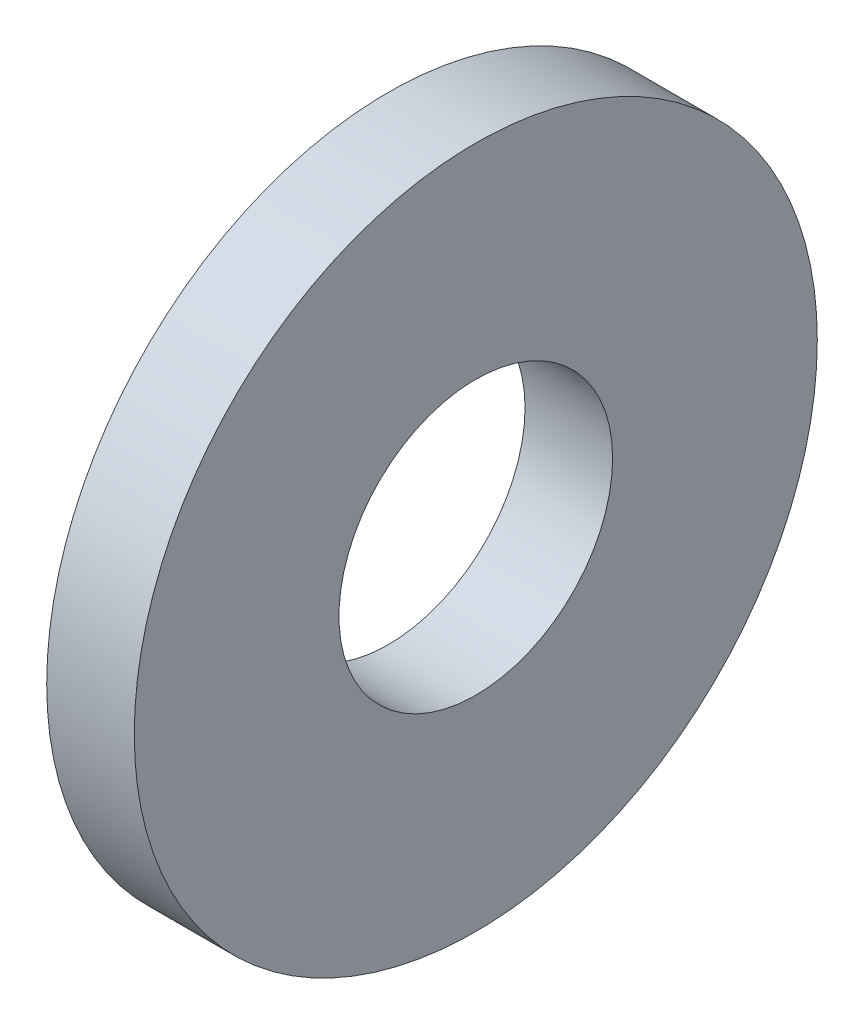
from build123d import *

# Parameters (mm, degrees)
SKETCH1_R           = 3.9624
SKETCH1_R_2         = 1.5875
BOSS_EXTRUDE1_DEPTH = 1.016


with BuildPart() as part:
    # Sketch1 → Boss-Extrude1 (new body)
    with BuildSketch(Plane(origin=(0, 0, 0), x_dir=(0, 0, -1), z_dir=(1, 0, 0))):
        Circle(SKETCH1_R)
        Circle(SKETCH1_R_2, mode=Mode.SUBTRACT)
    extrude(amount=BOSS_EXTRUDE1_DEPTH)


solid = part.part
